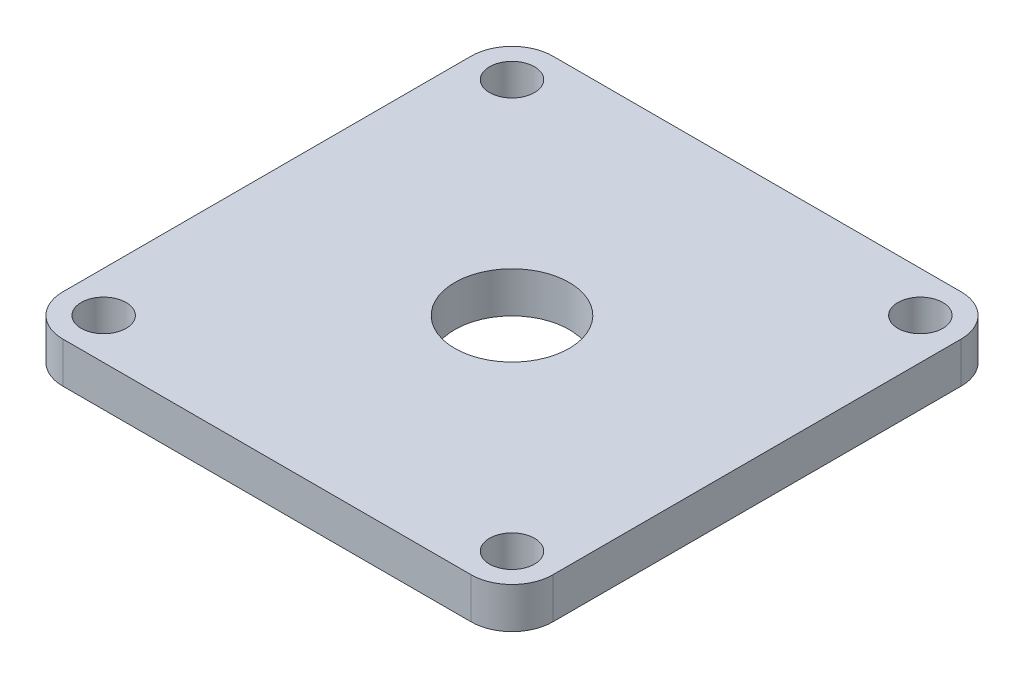
from build123d import *

# Parameters (mm, degrees)
SKETCH1_W           = 60
SKETCH1_H           = 60
BOSS_EXTRUDE1_DEPTH = 5
SKETCH2_R           = 2.75
CUT_EXTRUDE1_DEPTH  = 5
FILLET2_R           = 5
SKETCH3_R           = 7
CUT_EXTRUDE2_DEPTH  = 5


with BuildPart() as part:
    # Sketch1 → Boss-Extrude1 (new body)
    with BuildSketch(Plane(origin=(0, 0, 0), x_dir=(1, 0, 0), z_dir=(0, 1, 0))):
        Rectangle(SKETCH1_W, SKETCH1_H)
    extrude(amount=BOSS_EXTRUDE1_DEPTH)

    # Sketch2 → Cut-Extrude1 (cut)
    with BuildSketch(Plane(origin=(0, 5, 0), x_dir=(1, 0, 0), z_dir=(0, 1, 0))):
        with Locations((25, 25)):
            Circle(SKETCH2_R)
        with Locations((-25, 25)):
            Circle(SKETCH2_R)
        with Locations((-25, -25)):
            Circle(SKETCH2_R)
        with Locations((25, -25)):
            Circle(SKETCH2_R)
    extrude(amount=-CUT_EXTRUDE1_DEPTH, mode=Mode.SUBTRACT)

    # Fillet2
    fillet2_edges = [part.edges().sort_by_distance(p)[0] for p in [
        (-30, 2.5, -30),
        (30, 2.5, -30),
        (30, 2.5, 30),
        (-30, 2.5, 30),
    ]]
    fillet(fillet2_edges, radius=FILLET2_R)

    # Sketch3 → Cut-Extrude2 (cut)
    with BuildSketch(Plane(origin=(0, 5, 0), x_dir=(1, 0, 0), z_dir=(0, 1, 0))):
        Circle(SKETCH3_R)
    extrude(amount=-CUT_EXTRUDE2_DEPTH, mode=Mode.SUBTRACT)


solid = part.part
